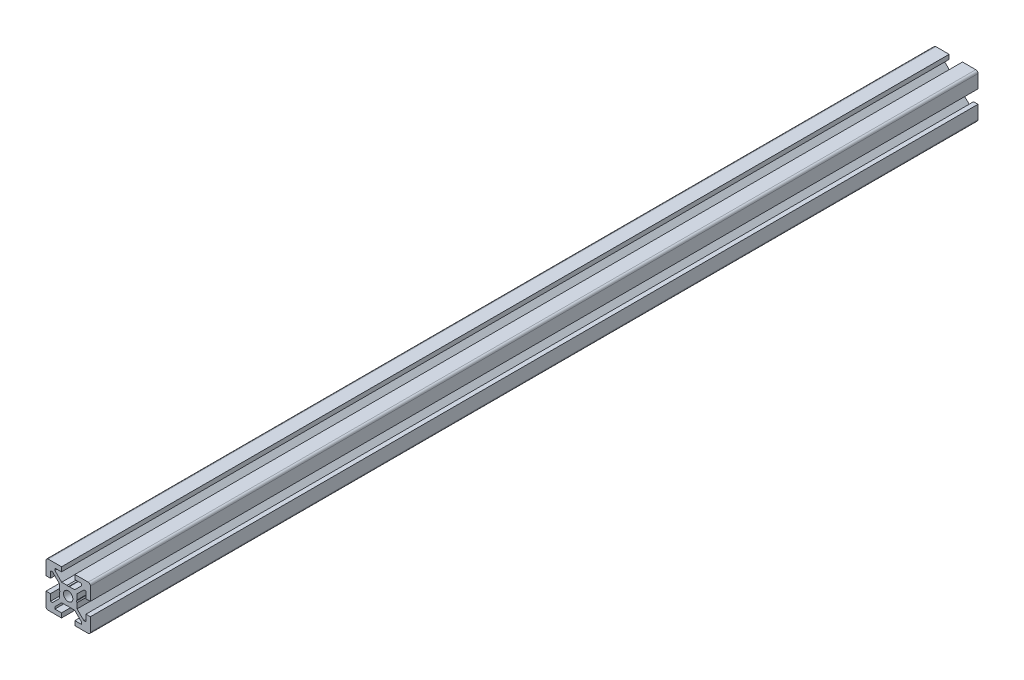
from build123d import *

# Parameters (mm, degrees)
SKETCH1_R           = 2.1
BOSS_EXTRUDE1_DEPTH = 350
SKETCH2_R           = 2.1
BOSS_EXTRUDE2_DEPTH = 50


with BuildPart() as part:
    # Sketch1 → Boss-Extrude1 (new body)
    with BuildSketch(Plane(origin=(0, 0, -350), x_dir=(-1, 0, 0), z_dir=(0, 0, -1))):
        with BuildLine():
            Line((8, -3), (8, -6))
            Line((8, -6), (7.060660172, -6))
            Line((7.060660172, -6), (4, -2.939339828))
            Line((4, -2.939339828), (4, -0.519615242))
            Line((4, -0.519615242), (3.7, 0))
            Line((3.7, 0), (4, 0.519615242))
            Line((4, 0.519615242), (4, 2.939339828))
            Line((4, 2.939339828), (7.060660172, 6))
            Line((7.060660172, 6), (8, 6))
            Line((8, 6), (8, 3))
            Line((8, 3), (10, 3))
            Line((10, 3), (10, 9))
            ThreePointArc((10, 9), (9.707106781, 9.707106781), (9, 10))
            Line((9, 10), (3, 10))
            Line((3, 10), (3, 8))
            Line((3, 8), (6, 8))
            Line((6, 8), (6, 7.060660172))
            Line((6, 7.060660172), (2.939339828, 4))
            Line((2.939339828, 4), (0.519615242, 4))
            Line((0.519615242, 4), (0, 3.7))
            Line((0, 3.7), (-0.519615242, 4))
            Line((-0.519615242, 4), (-2.939339828, 4))
            Line((-2.939339828, 4), (-6, 7.060660172))
            Line((-6, 7.060660172), (-6, 8))
            Line((-6, 8), (-3, 8))
            Line((-3, 8), (-3, 10))
            Line((-3, 10), (-9, 10))
            ThreePointArc((-9, 10), (-9.707106781, 9.707106781), (-10, 9))
            Line((-10, 9), (-10, 3))
            Line((-10, 3), (-8, 3))
            Line((-8, 3), (-8, 6))
            Line((-8, 6), (-7.060660172, 6))
            Line((-7.060660172, 6), (-4, 2.939339828))
            Line((-4, 2.939339828), (-4, 0.519615242))
            Line((-4, 0.519615242), (-3.7, 0))
            Line((-3.7, 0), (-4, -0.519615242))
            Line((-4, -0.519615242), (-4, -2.939339828))
            Line((-4, -2.939339828), (-7.060660172, -6))
            Line((-7.060660172, -6), (-8, -6))
            Line((-8, -6), (-8, -3))
            Line((-8, -3), (-10, -3))
            Line((-10, -3), (-10, -9))
            ThreePointArc((-10, -9), (-9.707106781, -9.707106781), (-9, -10))
            Line((-9, -10), (-3, -10))
            Line((-3, -10), (-3, -8))
            Line((-3, -8), (-6, -8))
            Line((-6, -8), (-6, -7.060660172))
            Line((-6, -7.060660172), (-2.939339828, -4))
            Line((-2.939339828, -4), (-0.519615242, -4))
            Line((-0.519615242, -4), (0, -3.7))
            Line((0, -3.7), (0.519615242, -4))
            Line((0.519615242, -4), (2.939339828, -4))
            Line((2.939339828, -4), (6, -7.060660172))
            Line((6, -7.060660172), (6, -8))
            Line((6, -8), (3, -8))
            Line((3, -8), (3, -10))
            Line((3, -10), (9, -10))
            ThreePointArc((9, -10), (9.707106781, -9.707106781), (10, -9))
            Line((10, -9), (10, -3))
            Line((10, -3), (8, -3))
        make_face()
        Circle(SKETCH1_R, mode=Mode.SUBTRACT)
    extrude(amount=-BOSS_EXTRUDE1_DEPTH)

    # Sketch2 → Boss-Extrude2 (add)
    with BuildSketch(Plane(origin=(0, 0, -350), x_dir=(-1, 0, 0), z_dir=(0, 0, -1))):
        with BuildLine():
            Line((10, -3), (8, -3))
            Line((8, -3), (8, -6))
            Line((8, -6), (7.060660172, -6))
            Line((7.060660172, -6), (4, -2.939339828))
            Line((4, -2.939339828), (4, -0.519615242))
            Line((4, -0.519615242), (3.7, 0))
            Line((3.7, 0), (4, 0.519615242))
            Line((4, 0.519615242), (4, 2.939339828))
            Line((4, 2.939339828), (7.060660172, 6))
            Line((7.060660172, 6), (8, 6))
            Line((8, 6), (8, 3))
            Line((8, 3), (10, 3))
            Line((10, 3), (10, 9))
            ThreePointArc((10, 9), (9.707106781, 9.707106781), (9, 10))
            Line((9, 10), (3, 10))
            Line((3, 10), (3, 8))
            Line((3, 8), (6, 8))
            Line((6, 8), (6, 7.060660172))
            Line((6, 7.060660172), (2.939339828, 4))
            Line((2.939339828, 4), (0.519615242, 4))
            Line((0.519615242, 4), (0, 3.7))
            Line((0, 3.7), (-0.519615242, 4))
            Line((-0.519615242, 4), (-2.939339828, 4))
            Line((-2.939339828, 4), (-6, 7.060660172))
            Line((-6, 7.060660172), (-6, 8))
            Line((-6, 8), (-3, 8))
            Line((-3, 8), (-3, 10))
            Line((-3, 10), (-9, 10))
            ThreePointArc((-9, 10), (-9.707106781, 9.707106781), (-10, 9))
            Line((-10, 9), (-10, 3))
            Line((-10, 3), (-8, 3))
            Line((-8, 3), (-8, 6))
            Line((-8, 6), (-7.060660172, 6))
            Line((-7.060660172, 6), (-4, 2.939339828))
            Line((-4, 2.939339828), (-4, 0.519615242))
            Line((-4, 0.519615242), (-3.7, 0))
            Line((-3.7, 0), (-4, -0.519615242))
            Line((-4, -0.519615242), (-4, -2.939339828))
            Line((-4, -2.939339828), (-7.060660172, -6))
            Line((-7.060660172, -6), (-8, -6))
            Line((-8, -6), (-8, -3))
            Line((-8, -3), (-10, -3))
            Line((-10, -3), (-10, -9))
            ThreePointArc((-10, -9), (-9.707106781, -9.707106781), (-9, -10))
            Line((-9, -10), (-3, -10))
            Line((-3, -10), (-3, -8))
            Line((-3, -8), (-6, -8))
            Line((-6, -8), (-6, -7.060660172))
            Line((-6, -7.060660172), (-2.939339828, -4))
            Line((-2.939339828, -4), (-0.519615242, -4))
            Line((-0.519615242, -4), (0, -3.7))
            Line((0, -3.7), (0.519615242, -4))
            Line((0.519615242, -4), (2.939339828, -4))
            Line((2.939339828, -4), (6, -7.060660172))
            Line((6, -7.060660172), (6, -8))
            Line((6, -8), (3, -8))
            Line((3, -8), (3, -10))
            Line((3, -10), (9, -10))
            ThreePointArc((9, -10), (9.707106781, -9.707106781), (10, -9))
            Line((10, -9), (10, -3))
        make_face()
        Circle(SKETCH2_R, mode=Mode.SUBTRACT)
    extrude(amount=BOSS_EXTRUDE2_DEPTH)


solid = part.part
